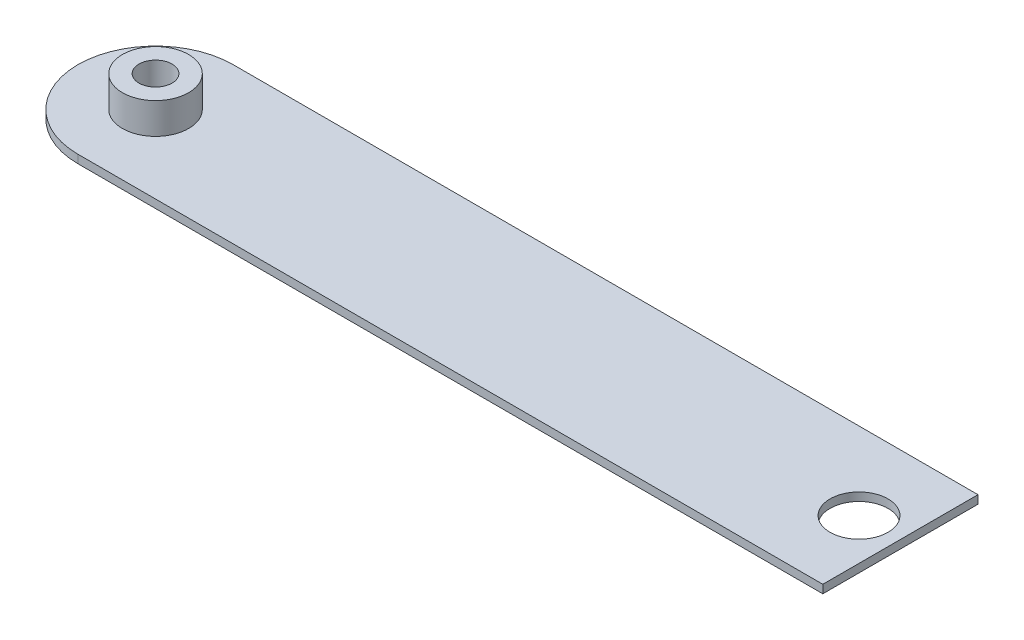
from build123d import *

# Parameters (mm, degrees)
BOSS_EXTRUDE1_DEPTH = 2
SKETCH2_R           = 1.6
CUT_EXTRUDE1_DEPTH  = 1.8
SKETCH3_R           = 0.8
CUT_EXTRUDE2_DEPTH  = 3
SKETCH4_R           = 2.8
CUT_EXTRUDE3_DEPTH  = 1.4
SKETCH5_R           = 3.2
SKETCH5_R_2         = 1.6
BOSS_EXTRUDE2_DEPTH = 3
SKETCH6_W           = 80.029728654
SKETCH6_H           = 15
CUT_EXTRUDE4_DEPTH  = 1.2


with BuildPart() as part:
    # Sketch1 → Boss-Extrude1 (new body)
    with BuildSketch(Plane(origin=(0, 0, 0), x_dir=(1, 0, 0), z_dir=(0, 1, 0))):
        with BuildLine():
            ThreePointArc((7.5, 0), (5.303300859, -5.303300859), (0, -7.5))
            Line((0, -7.5), (72, -7.5))
            Line((72, -7.5), (72, 7.5))
            Line((72, 7.5), (0, 7.5))
            ThreePointArc((0, 7.5), (5.303300859, 5.303300859), (7.5, 0))
        make_face()
        with BuildLine():
            ThreePointArc((0, 7.5), (-7.5, 0), (0, -7.5))
            Line((0, -7.5), (0, 7.5))
        make_face()
        with BuildLine():
            Line((0, 7.5), (0, -7.5))
            ThreePointArc((0, -7.5), (5.303300859, -5.303300859), (7.5, 0))
            ThreePointArc((7.5, 0), (5.303300859, 5.303300859), (0, 7.5))
        make_face()
    extrude(amount=BOSS_EXTRUDE1_DEPTH)

    # Sketch2 → Cut-Extrude1 (cut)
    with BuildSketch(Plane(origin=(0, 2, 0), x_dir=(1, 0, 0), z_dir=(0, 1, 0))):
        Circle(SKETCH2_R)
    extrude(amount=-CUT_EXTRUDE1_DEPTH, mode=Mode.SUBTRACT)

    # Sketch3 → Cut-Extrude2 (cut)
    with BuildSketch(Plane(origin=(0, 0.2, 0), x_dir=(1, 0, 0), z_dir=(0, 1, 0))):
        Circle(SKETCH3_R)
    extrude(amount=-CUT_EXTRUDE2_DEPTH, mode=Mode.SUBTRACT)

    # Sketch4 → Cut-Extrude3 (cut)
    with BuildSketch(Plane(origin=(0, 2, 0), x_dir=(1, 0, 0), z_dir=(0, 1, 0))):
        with Locations((68, 0)):
            Circle(SKETCH4_R)
    extrude(amount=-CUT_EXTRUDE3_DEPTH, mode=Mode.SUBTRACT)

    # Sketch5 → Boss-Extrude2 (add)
    with BuildSketch(Plane(origin=(0, 2, 0), x_dir=(1, 0, 0), z_dir=(0, 1, 0))):
        Circle(SKETCH5_R)
        Circle(SKETCH5_R_2, mode=Mode.SUBTRACT)
    extrude(amount=BOSS_EXTRUDE2_DEPTH)

    # Sketch6 → Cut-Extrude4 (cut)
    with BuildSketch(Plane.XZ):
        with Locations((31.985135673, 0)):
            Rectangle(SKETCH6_W, SKETCH6_H)
    extrude(amount=-CUT_EXTRUDE4_DEPTH, mode=Mode.SUBTRACT)


solid = part.part
